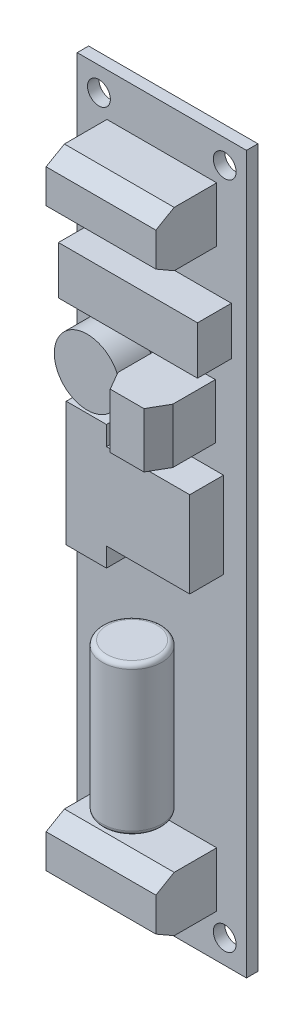
from build123d import *

# Parameters (mm, degrees)
SKETCH1_W             = 23.5
SKETCH1_H             = 99.5
BOSS_EXTRUDE1_DEPTH   = 1.5875
SKETCH2_R             = 1.5875
CUT_EXTRUDE1_DEPTH    = 2.5875
SKETCH5_W             = 15.24
SKETCH5_H             = 7.62
SKETCH5_W_2           = 7.62
BOSS_EXTRUDE2_DEPTH   = 8.4455
CHAMFER1_SIZE         = 2.54
CHAMFER1_SIZE2        = 1.466469684
CHAMFER1_PART_2_SIZE  = 2.54
CHAMFER1_PART_2_SIZE2 = 1.466469684
CHAMFER1_PART_3_SIZE  = 2.54
CHAMFER1_PART_3_SIZE2 = 1.466469684
CHAMFER1_PART_4_SIZE  = 2.54
CHAMFER1_PART_4_SIZE2 = 1.466469684
CHAMFER1_PART_5_SIZE  = 2.54
CHAMFER1_PART_5_SIZE2 = 1.466469684
CHAMFER1_PART_6_SIZE  = 2.54
CHAMFER1_PART_6_SIZE2 = 1.466469684
SKETCH6_R             = 4.1275
BOSS_EXTRUDE3_DEPTH   = 20.701
FILLET1_R             = 0.635
SKETCH7_R             = 4.572
SKETCH7_W             = 19.304
SKETCH7_H             = 6.6675
BOSS_EXTRUDE4_DEPTH   = 4.699


with BuildPart() as part:
    # Sketch1 → Boss-Extrude1 (new body)
    with BuildSketch(Plane.XY):
        with Locations((11.75, -49.75)):
            Rectangle(SKETCH1_W, SKETCH1_H)
    extrude(amount=BOSS_EXTRUDE1_DEPTH)

    # Sketch2 → Cut-Extrude1 (cut, through all)
    with BuildSketch(Plane(origin=(0, 0, 0), x_dir=(-1, 0, 0), z_dir=(0, 0, -1))):
        with Locations((-20.48125, -3.315625)):
            Circle(SKETCH2_R)
        with Locations((-3.01875, -3.315625)):
            Circle(SKETCH2_R)
        with Locations((-3.01875, -96.184375)):
            Circle(SKETCH2_R)
        with Locations((-20.48125, -96.184375)):
            Circle(SKETCH2_R)
    extrude(amount=-CUT_EXTRUDE1_DEPTH, mode=Mode.SUBTRACT)

    # Sketch5 → Boss-Extrude2 (add)
    with BuildSketch(Plane.XY.offset(1.5875)):
        with Locations((11.75, -9.779)):
            Rectangle(SKETCH5_W, SKETCH5_H)
        with Locations((15.372, -33.528)):
            Rectangle(SKETCH5_W_2, SKETCH5_H)
        with Locations((11.75, -89.721)):
            Rectangle(SKETCH5_W, SKETCH5_H)
    extrude(amount=BOSS_EXTRUDE2_DEPTH)

    # Chamfer1
    chamfer1_edges = [part.edges().sort_by_distance(p)[0] for p in [
        (11.75, -13.589, 10.033),
    ]]
    chamfer1_side = [part.faces().sort_by_distance(p)[0] for p in [
        (11.75, -13.589, 5.81025),
    ]]
    chamfer(chamfer1_edges, length=CHAMFER1_SIZE, length2=CHAMFER1_SIZE2, reference=chamfer1_side[0])

    # Chamfer1 part 2
    chamfer1_part_2_edges = [part.edges().sort_by_distance(p)[0] for p in [
        (11.75, -5.969, 10.033),
    ]]
    chamfer1_part_2_side = [part.faces().sort_by_distance(p)[0] for p in [
        (11.75, -5.969, 5.81025),
    ]]
    chamfer(chamfer1_part_2_edges, length=CHAMFER1_PART_2_SIZE, length2=CHAMFER1_PART_2_SIZE2, reference=chamfer1_part_2_side[0])

    # Chamfer1 part 3
    chamfer1_part_3_edges = [part.edges().sort_by_distance(p)[0] for p in [
        (11.562, -33.528, 10.033),
    ]]
    chamfer1_part_3_side = [part.faces().sort_by_distance(p)[0] for p in [
        (11.562, -33.528, 5.81025),
    ]]
    chamfer(chamfer1_part_3_edges, length=CHAMFER1_PART_3_SIZE, length2=CHAMFER1_PART_3_SIZE2, reference=chamfer1_part_3_side[0])

    # Chamfer1 part 4
    chamfer1_part_4_edges = [part.edges().sort_by_distance(p)[0] for p in [
        (19.182, -33.528, 10.033),
    ]]
    chamfer1_part_4_side = [part.faces().sort_by_distance(p)[0] for p in [
        (19.182, -33.528, 5.81025),
    ]]
    chamfer(chamfer1_part_4_edges, length=CHAMFER1_PART_4_SIZE, length2=CHAMFER1_PART_4_SIZE2, reference=chamfer1_part_4_side[0])

    # Chamfer1 part 5
    chamfer1_part_5_edges = [part.edges().sort_by_distance(p)[0] for p in [
        (11.75, -93.531, 10.033),
    ]]
    chamfer1_part_5_side = [part.faces().sort_by_distance(p)[0] for p in [
        (11.75, -93.531, 5.81025),
    ]]
    chamfer(chamfer1_part_5_edges, length=CHAMFER1_PART_5_SIZE, length2=CHAMFER1_PART_5_SIZE2, reference=chamfer1_part_5_side[0])

    # Chamfer1 part 6
    chamfer1_part_6_edges = [part.edges().sort_by_distance(p)[0] for p in [
        (11.75, -85.911, 10.033),
    ]]
    chamfer1_part_6_side = [part.faces().sort_by_distance(p)[0] for p in [
        (11.75, -85.911, 5.81025),
    ]]
    chamfer(chamfer1_part_6_edges, length=CHAMFER1_PART_6_SIZE, length2=CHAMFER1_PART_6_SIZE2, reference=chamfer1_part_6_side[0])

    # Sketch7 → Boss-Extrude4 (add)
    with BuildSketch(Plane.XY.offset(1.5875)):
        with Locations((6.096, -33.02)):
            Circle(SKETCH7_R)
        with Locations((11.75, -22.76475)):
            Rectangle(SKETCH7_W, SKETCH7_H)
        Polygon((8.7655, -52.578), (8.7655, -55.245), (3.1775, -55.245), (3.1775, -37.973), (8.7655, -37.973), (8.7655, -40.64), (20.3225, -40.64), (20.3225, -52.578), align=None)
    extrude(amount=BOSS_EXTRUDE4_DEPTH)


with BuildPart() as body_2:
    # Sketch6 → Boss-Extrude3 (new body)
    with BuildSketch(Plane(origin=(0, -83.371, 0), x_dir=(1, 0, 0), z_dir=(0, 1, 0))):
        with Locations((11.75, -5.715)):
            Circle(SKETCH6_R)
    extrude(amount=BOSS_EXTRUDE3_DEPTH)

    # Fillet1
    fillet1_edges = [body_2.edges().sort_by_distance(p)[0] for p in [
        (7.6225, -83.371, 5.715),
        (7.6225, -62.67, 5.715),
    ]]
    fillet(fillet1_edges, radius=FILLET1_R)


solid = Compound([part.part, body_2.part])
